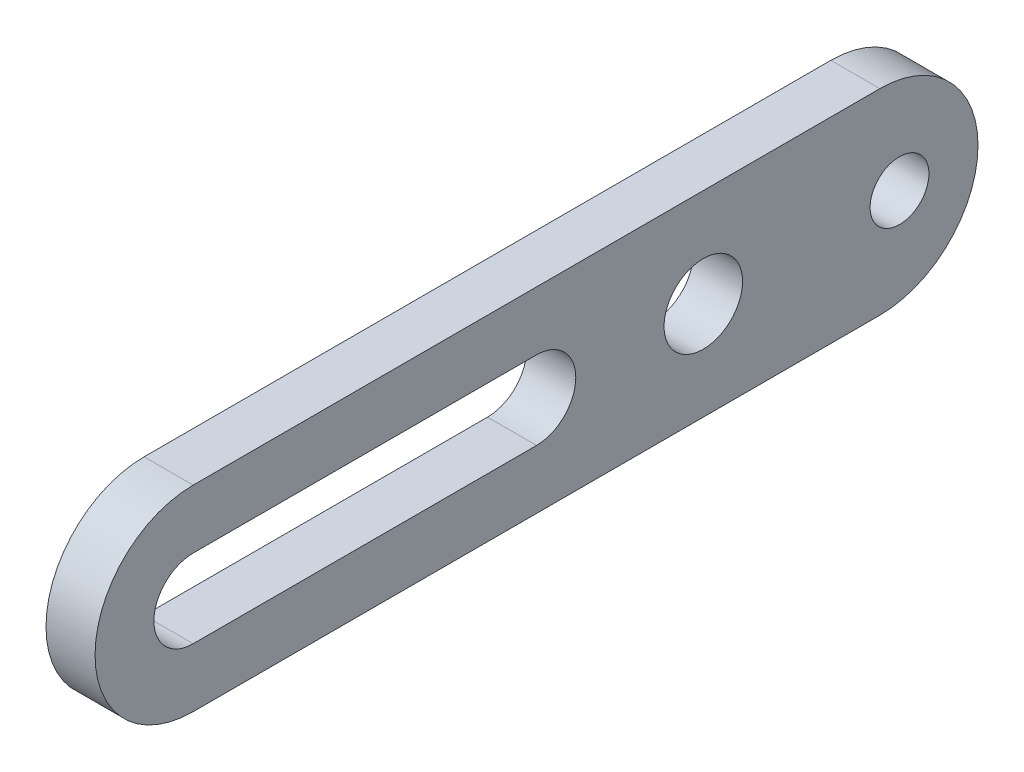
from build123d import *

# Parameters (mm, degrees)
BOSS_EXTRUDE1_DEPTH = 5
SKETCH2_R           = 4
SKETCH2_R_2         = 3
CUT_EXTRUDE1_DEPTH  = 6


with BuildPart() as part:
    # Sketch1 → Boss-Extrude1 (new body)
    with BuildSketch(Plane(origin=(0, 0, 0), x_dir=(0, 0, -1), z_dir=(1, 0, 0))):
        with BuildLine():
            Line((-35, 10), (35, 10))
            ThreePointArc((35, 10), (45, 0), (35, -10))
            Line((35, -10), (-35, -10))
            ThreePointArc((-35, -10), (-45, 0), (-35, 10))
        make_face()
    extrude(amount=BOSS_EXTRUDE1_DEPTH)

    # Sketch2 → Cut-Extrude1 (cut, through all)
    with BuildSketch(Plane(origin=(5, 0, 0), x_dir=(0, 0, -1), z_dir=(1, 0, 0))):
        with Locations((17, 0)):
            Circle(SKETCH2_R)
        with Locations((37, 0)):
            Circle(SKETCH2_R_2)
        with BuildLine():
            Line((-35, 4), (0, 4))
            ThreePointArc((0, 4), (4, 0), (0, -4))
            Line((0, -4), (-35, -4))
            ThreePointArc((-35, -4), (-39, 0), (-35, 4))
        make_face()
    extrude(amount=-CUT_EXTRUDE1_DEPTH, mode=Mode.SUBTRACT)


solid = part.part
